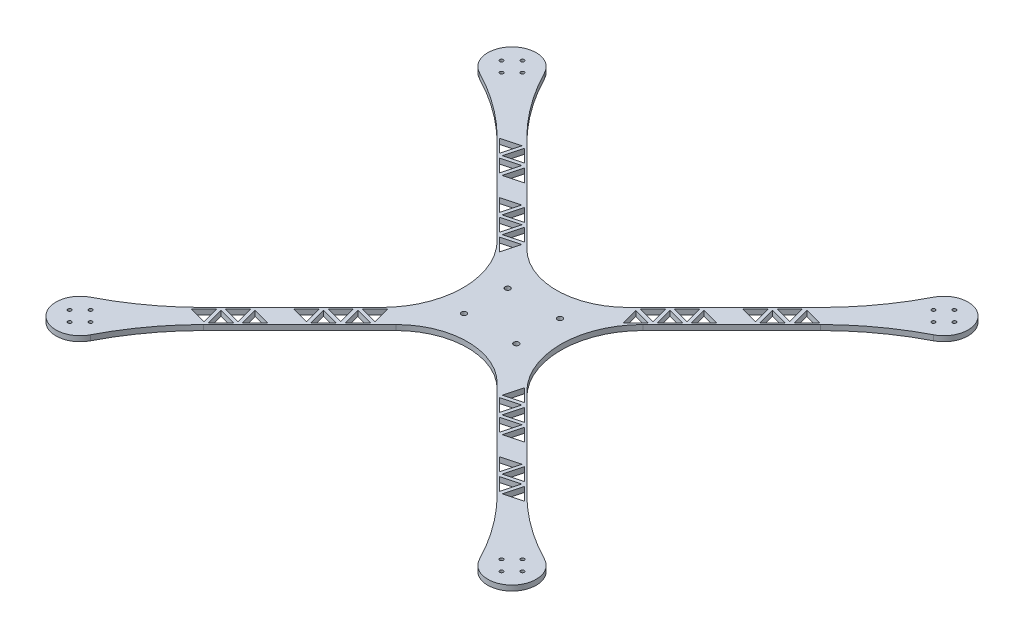
from build123d import *

# Parameters (mm, degrees)
SKETCH1_R           = 1
SKETCH1_R_2         = 1.5
BOSS_EXTRUDE1_DEPTH = 3
CUT_EXTRUDE1_DEPTH  = 10


with BuildPart() as part:
    # Sketch1 → Boss-Extrude1 (new body)
    with BuildSketch(Plane(origin=(0, 0, 0), x_dir=(1, 0, 0), z_dir=(0, 1, 0))):
        with BuildLine():
            Line((-41.798989873, -33.313708499), (-92.630988335, -84.145706961))
            ThreePointArc((-92.630988335, -84.145706961), (-110.283870137, -99.243324857), (-130.064772279, -111.420279013))
            ThreePointArc((-130.064772279, -111.420279013), (-133.537115627, -133.537115627), (-111.420279013, -130.064772279))
            ThreePointArc((-111.420279013, -130.064772279), (-99.243324857, -110.283870137), (-84.145706961, -92.630988335))
            Line((-84.145706961, -92.630988335), (-29.045941546, -37.53122292))
            ThreePointArc((-29.045941546, -37.53122292), (-15.71955029, -28.626812962), (0, -25.5))
            ThreePointArc((0, -25.5), (15.71955029, -28.626812962), (29.045941546, -37.53122292))
            Line((29.045941546, -37.53122292), (84.145706961, -92.630988335))
            ThreePointArc((84.145706961, -92.630988335), (99.243324857, -110.283870137), (111.420279013, -130.064772279))
            ThreePointArc((111.420279013, -130.064772279), (133.537115627, -133.537115627), (130.064772279, -111.420279013))
            ThreePointArc((130.064772279, -111.420279013), (110.283870137, -99.243324857), (92.630988335, -84.145706961))
            Line((92.630988335, -84.145706961), (41.798989873, -33.313708499))
            ThreePointArc((41.798989873, -33.313708499), (31.586240625, -18.029249121), (28, 0))
            ThreePointArc((28, 0), (31.586240625, 18.029249121), (41.798989873, 33.313708499))
            Line((41.798989873, 33.313708499), (92.630988335, 84.145706961))
            ThreePointArc((92.630988335, 84.145706961), (110.283870137, 99.243324857), (130.064772279, 111.420279013))
            ThreePointArc((130.064772279, 111.420279013), (133.537115627, 133.537115627), (111.420279013, 130.064772279))
            ThreePointArc((111.420279013, 130.064772279), (99.243324857, 110.283870137), (84.145706961, 92.630988335))
            Line((84.145706961, 92.630988335), (29.045941546, 37.53122292))
            ThreePointArc((29.045941546, 37.53122292), (15.71955029, 28.626812962), (0, 25.5))
            ThreePointArc((0, 25.5), (-15.71955029, 28.626812962), (-29.045941546, 37.53122292))
            Line((-29.045941546, 37.53122292), (-84.145706961, 92.630988335))
            ThreePointArc((-84.145706961, 92.630988335), (-99.243324857, 110.283870137), (-111.420279013, 130.064772279))
            ThreePointArc((-111.420279013, 130.064772279), (-133.537115627, 133.537115627), (-130.064772279, 111.420279013))
            ThreePointArc((-130.064772279, 111.420279013), (-110.283870137, 99.243324857), (-92.630988335, 84.145706961))
            Line((-92.630988335, 84.145706961), (-41.798989873, 33.313708499))
            ThreePointArc((-41.798989873, 33.313708499), (-31.586240625, 18.029249121), (-28, 0))
            ThreePointArc((-28, 0), (-31.586240625, -18.029249121), (-41.798989873, -33.313708499))
        make_face()
        with Locations((-123.743686708, -129.743686708)):
            Circle(SKETCH1_R, mode=Mode.SUBTRACT)
        with Locations((-129.743686708, -123.743686708)):
            Circle(SKETCH1_R, mode=Mode.SUBTRACT)
        with Locations((-117.743686708, -123.743686708)):
            Circle(SKETCH1_R, mode=Mode.SUBTRACT)
        with Locations((-123.743686708, -117.743686708)):
            Circle(SKETCH1_R, mode=Mode.SUBTRACT)
        with Locations((-15, -12.5)):
            Circle(SKETCH1_R_2, mode=Mode.SUBTRACT)
        with Locations((117.743686708, -123.743686708)):
            Circle(SKETCH1_R, mode=Mode.SUBTRACT)
        with Locations((123.743686708, -129.743686708)):
            Circle(SKETCH1_R, mode=Mode.SUBTRACT)
        with Locations((129.743686708, -123.743686708)):
            Circle(SKETCH1_R, mode=Mode.SUBTRACT)
        with Locations((123.743686708, -117.743686708)):
            Circle(SKETCH1_R, mode=Mode.SUBTRACT)
        with Locations((15, -12.5)):
            Circle(SKETCH1_R_2, mode=Mode.SUBTRACT)
        with Locations((-15, 12.5)):
            Circle(SKETCH1_R_2, mode=Mode.SUBTRACT)
        with Locations((-123.743686708, 117.743686708)):
            Circle(SKETCH1_R, mode=Mode.SUBTRACT)
        with Locations((-129.743686708, 123.743686708)):
            Circle(SKETCH1_R, mode=Mode.SUBTRACT)
        with Locations((-123.743686708, 129.743686708)):
            Circle(SKETCH1_R, mode=Mode.SUBTRACT)
        with Locations((-117.743686708, 123.743686708)):
            Circle(SKETCH1_R, mode=Mode.SUBTRACT)
        with Locations((15, 12.5)):
            Circle(SKETCH1_R_2, mode=Mode.SUBTRACT)
        with Locations((129.743686708, 123.743686708)):
            Circle(SKETCH1_R, mode=Mode.SUBTRACT)
        with Locations((117.743686708, 123.743686708)):
            Circle(SKETCH1_R, mode=Mode.SUBTRACT)
        with Locations((123.743686708, 117.743686708)):
            Circle(SKETCH1_R, mode=Mode.SUBTRACT)
        with Locations((123.743686708, 129.743686708)):
            Circle(SKETCH1_R, mode=Mode.SUBTRACT)
    extrude(amount=BOSS_EXTRUDE1_DEPTH)

    # Sketch3 → Cut-Extrude1 (cut)
    with BuildSketch(Plane(origin=(0, 3, 0), x_dir=(1, 0, 0), z_dir=(0, 1, 0))):
        Polygon((-42.669965912, 35.5988981), (-35.321496683, 28.250428872), (-32.631770267, 38.288624516), align=None)
        Polygon((-40.500418602, 47.571486413), (-33.149408357, 40.220476169), (-43.191075095, 37.529819676), align=None)
        Polygon((-52.470465899, 45.399398087), (-45.121996671, 38.050928859), (-42.432270254, 48.089124504), align=None)
        Polygon((-50.300918589, 57.371986401), (-42.949908344, 50.020976156), (-52.991575082, 47.330319663), align=None)
        Polygon((-62.270965886, 55.199898074), (-54.922496658, 47.851428846), (-52.232770241, 57.889624491), align=None)
        Polygon((-72.592575056, 66.931319638), (-69.901918563, 76.972986375), (-62.550908319, 69.621976131), align=None)
        Polygon((-81.871965861, 74.800898049), (-74.523496632, 67.452428821), (-71.833770216, 77.490624465), align=None)
        Polygon((-82.393075044, 76.731819625), (-79.702418551, 86.773486362), (-72.351408306, 79.422476118), align=None)
        Polygon((-91.672465848, 84.601398036), (-84.32399662, 77.252928808), (-81.634270203, 87.291124453), align=None)
        Polygon((81.634270203, 87.291124453), (91.672465848, 84.601398036), (84.32399662, 77.252928808), align=None)
        Polygon((82.393075044, 76.731819625), (79.702418551, 86.773486362), (72.351408306, 79.422476118), align=None)
        Polygon((71.833770216, 77.490624465), (81.871965861, 74.800898049), (74.523496632, 67.452428821), align=None)
        Polygon((69.901918563, 76.972986375), (62.550908319, 69.621976131), (72.592575056, 66.931319638), align=None)
        Polygon((52.232770241, 57.889624491), (62.270965886, 55.199898074), (54.922496658, 47.851428846), align=None)
        Polygon((42.949908344, 50.020976156), (52.991575082, 47.330319663), (50.300918589, 57.371986401), align=None)
        Polygon((42.432270254, 48.089124504), (52.470465899, 45.399398087), (45.121996671, 38.050928859), align=None)
        Polygon((40.500418602, 47.571486413), (33.149408357, 40.220476169), (43.191075095, 37.529819676), align=None)
        Polygon((32.631770267, 38.288624516), (42.669965912, 35.5988981), (35.321496683, 28.250428872), align=None)
        Polygon((95.493257836, -88.422190024), (85.455062191, -91.111916441), (88.144788608, -81.073720796), align=None)
        Polygon((83.523210539, -90.594278351), (86.213867032, -80.552611613), (76.172200294, -83.243268106), align=None)
        Polygon((75.654562204, -81.311416453), (78.34428862, -71.273220809), (85.692757849, -78.621690037), align=None)
        Polygon((73.722710551, -80.793778363), (76.413367044, -70.752111626), (66.371700307, -73.442768119), align=None)
        Polygon((66.091757874, -59.020690062), (56.053562229, -61.710416479), (58.743288646, -51.672220834), align=None)
        Polygon((56.81236707, -51.151111651), (46.770700332, -53.841768144), (54.121710577, -61.192778389), align=None)
        Polygon((48.942788659, -41.871720847), (56.291257887, -49.220190075), (46.253062242, -51.909916492), align=None)
        Polygon((36.970200345, -44.041268157), (44.32121059, -51.392278402), (47.011867083, -41.350611664), align=None)
        Polygon((46.4907579, -39.419690088), (36.452562255, -42.109416504), (39.142288672, -32.07122086), align=None)
        Polygon((-95.493257836, -88.422190024), (-85.455062191, -91.111916441), (-88.144788608, -81.073720796), align=None)
        Polygon((-76.172200294, -83.243268106), (-83.523210539, -90.594278351), (-86.213867032, -80.552611613), align=None)
        Polygon((-75.654562204, -81.311416453), (-78.34428862, -71.273220809), (-85.692757849, -78.621690037), align=None)
        Polygon((-73.722710551, -80.793778363), (-76.413367044, -70.752111626), (-66.371700307, -73.442768119), align=None)
        Polygon((-66.091757874, -59.020690062), (-56.053562229, -61.710416479), (-58.743288646, -51.672220834), align=None)
        Polygon((-54.121710577, -61.192778389), (-56.81236707, -51.151111651), (-46.770700332, -53.841768144), align=None)
        Polygon((-56.291257887, -49.220190075), (-46.253062242, -51.909916492), (-48.942788659, -41.871720847), align=None)
        Polygon((-36.970200345, -44.041268157), (-44.32121059, -51.392278402), (-47.011867083, -41.350611664), align=None)
        Polygon((-46.4907579, -39.419690088), (-36.452562255, -42.109416504), (-39.142288672, -32.07122086), align=None)
    extrude(amount=-CUT_EXTRUDE1_DEPTH, mode=Mode.SUBTRACT)


solid = part.part
